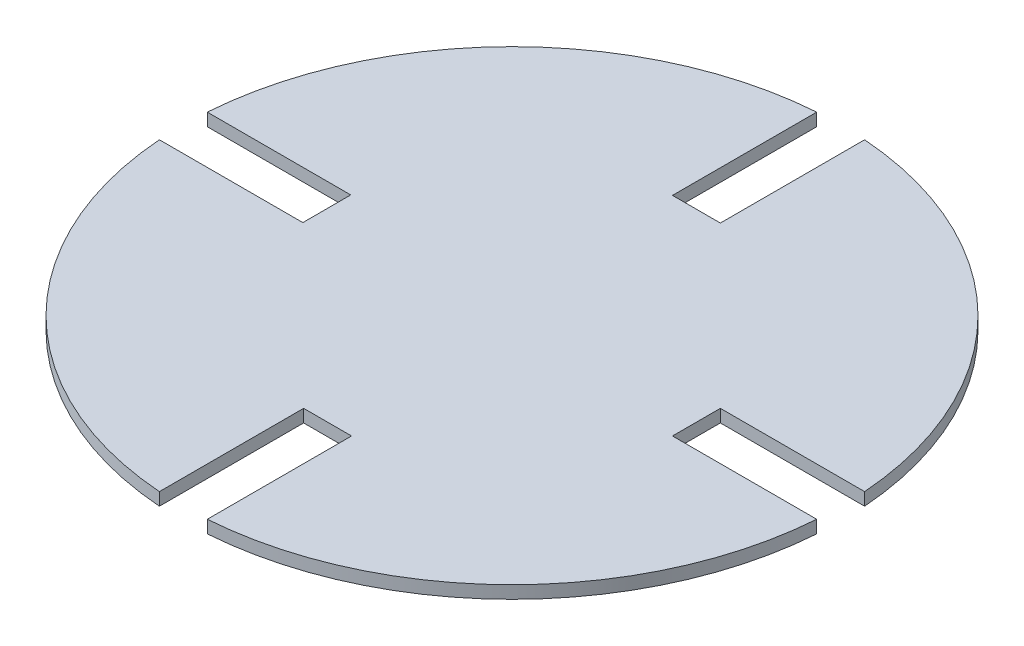
from build123d import *

# Parameters (mm, degrees)
SKETCH1_R           = 82.55
BOSS_EXTRUDE1_DEPTH = 3.175
SKETCH2_W           = 59.59856
SKETCH2_H           = 12.0000014
SKETCH2_W_2         = 59.99988
SKETCH2_W_3         = 12.0000014
SKETCH2_H_2         = 59.99988
CUT_EXTRUDE1_DEPTH  = 3.175


with BuildPart() as part:
    # Sketch1 → Boss-Extrude1 (new body)
    with BuildSketch(Plane(origin=(0, 0, 0), x_dir=(1, 0, 0), z_dir=(0, 1, 0))):
        Circle(SKETCH1_R)
    extrude(amount=BOSS_EXTRUDE1_DEPTH)

    # Sketch2 → Cut-Extrude1 (cut)
    with BuildSketch(Plane(origin=(0, 3.175, 0), x_dir=(1, 0, 0), z_dir=(0, 1, 0))):
        with Locations((-76.2, 0)):
            Rectangle(SKETCH2_W, SKETCH2_H)
        with Locations((76.2, 0)):
            Rectangle(SKETCH2_W_2, SKETCH2_H)
        with Locations((0, 76.2)):
            Rectangle(SKETCH2_W_3, SKETCH2_H_2)
        with Locations((0, -76.2)):
            Rectangle(SKETCH2_W_3, SKETCH2_H_2)
    extrude(amount=-CUT_EXTRUDE1_DEPTH, mode=Mode.SUBTRACT)


solid = part.part
